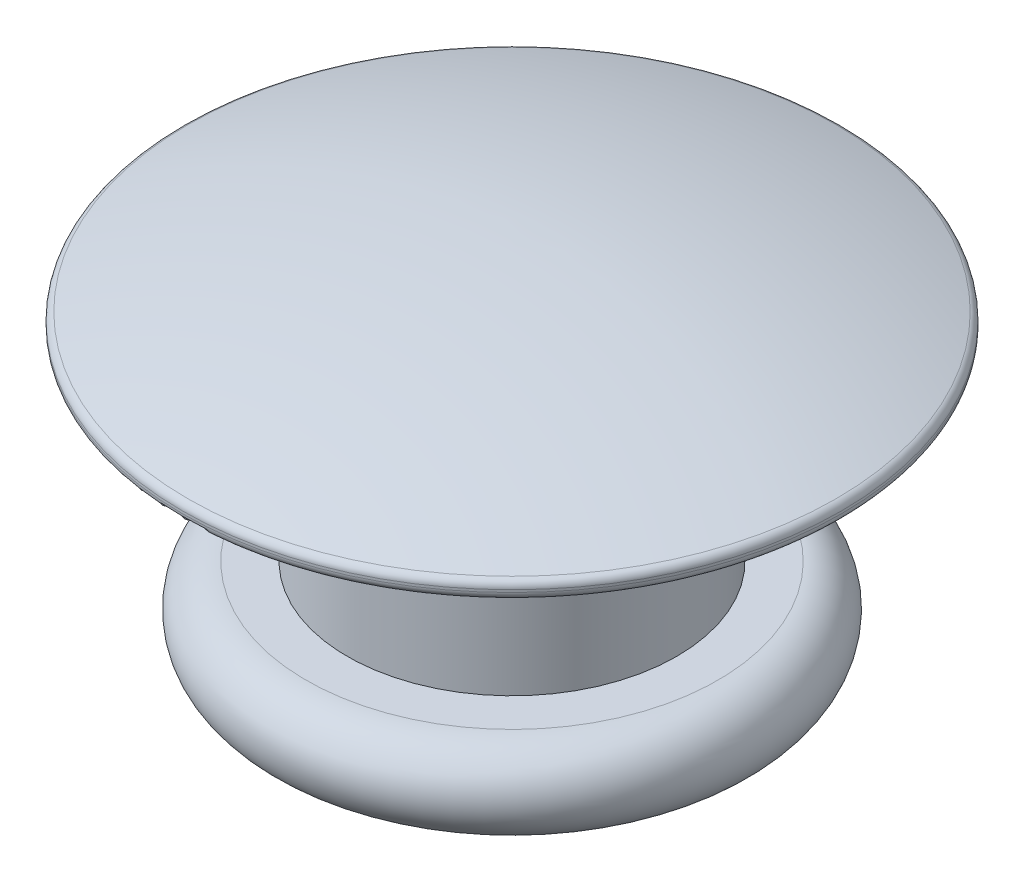
from build123d import *


with BuildPart() as part:
    # Sketch1 → Revolve1 (revolve)
    with BuildSketch(Plane.XY):
        with BuildLine():
            Line((4, 0.129563319), (4, 0.1))
            ThreePointArc((4, 0.1), (3.970710678, 0.029289322), (3.9, 0))
            Line((3.9, 0), (2, 0))
            Line((2, 0), (2, -2.4))
            Line((2, -2.4), (2.5, -2.4))
            ThreePointArc((2.5, -2.4), (3, -2.9), (2.5, -3.4))
            Line((2.5, -3.4), (1.9, -3.4))
            ThreePointArc((1.9, -3.4), (1.546446609, -3.253553391), (1.4, -2.9))
            Line((1.4, -2.9), (0, -2.9))
            Line((0, -2.9), (0, 0.9))
            ThreePointArc((0, 0.9), (1.99554555, 0.729724866), (3.933394495, 0.223822576))
            ThreePointArc((3.933394495, 0.223822576), (3.981668383, 0.187271856), (4, 0.129563319))
        make_face()
    revolve(axis=Axis((0, 0, 0), (0, -1, 0)))


solid = part.part
